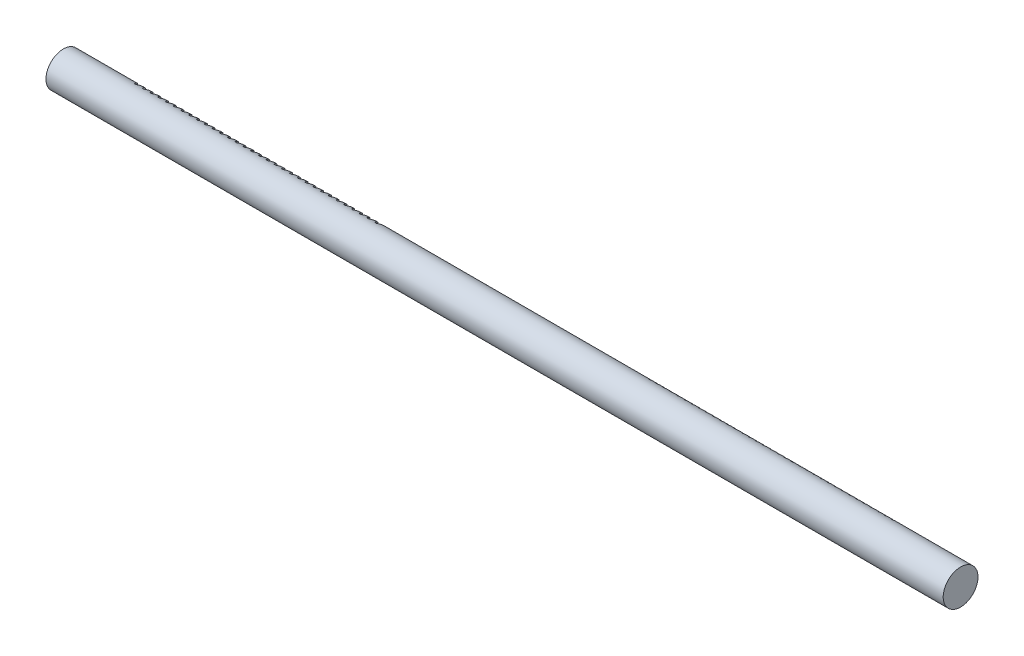
from build123d import *

# Parameters (mm, degrees)
SKIZZE2_W                                           = 670
SKIZZE2_H                                           = 13
SCHNITT_LINEAR_AUSTRAGEN1_ZAHNSTANGE_LEN_DEPTH      = 14
SCHNITT_LINEAR_AUSTRAGEN1_ZAHNSTANGE_LEN_DEPTH_BACK = 14
SCHNITT_LINEAR_AUSTRAGEN_ZAHNSTANGE_SERV_DEPTH      = 16.241670442
SCHNITT_LINEAR_AUSTRAGEN_ZAHNSTANGE_SERV_DEPTH_BACK = 16.241670442


with BuildPart() as part:
    # Skizze2 → Rotation1 (revolve)
    with BuildSketch(Plane(origin=(0, 0, 0), x_dir=(-1, 0, 0), z_dir=(0, 0, -1)), mode=Mode.PRIVATE) as rotation1_sk:
        with Locations((-308.521326768, 6.5)):
            Rectangle(SKIZZE2_W, SKIZZE2_H)
    revolve(rotation1_sk.sketch.rotate(Axis((643.521326768, 0, 0), (-1, 0, 0)), 90), axis=Axis((643.521326768, 0, 0), (-1, 0, 0)))  # turned: the seam where the file's is

    # Skizze6 → Schnitt-Linear austragen1 Zahnstange Len (cut, two sides)
    with BuildSketch(Plane(origin=(0, 0, 0), x_dir=(1, 0, 0), z_dir=(0, 1, 0))) as schnitt_linear_austragen1_zahnstange_len_sk:
        with BuildLine():
            Line((209.521326768, 13), (15.521326768, 13))
            Line((15.521326768, 13), (15.773805143, 9.389391013))
            Line((15.773805143, 9.389391013), (15.891244262, 9.14))
            Line((15.891244262, 9.14), (19.808375476, 9.14))
            Line((19.808375476, 9.14), (19.908375476, 9.04))
            Line((19.908375476, 9.04), (21.28637707, 5.253971735))
            ThreePointArc((21.28637707, 5.253971735), (21.397662113, 5.108942244), (21.572006982, 5.053971518))
            Line((21.572006982, 5.053971518), (22.55552966, 5.053971518))
            ThreePointArc((22.55552966, 5.053971518), (22.729874528, 5.108942244), (22.841159571, 5.253971735))
            Line((22.841159571, 5.253971735), (24.182764142, 8.94))
            ThreePointArc((24.182764142, 8.94), (24.294049064, 9.085029334), (24.468393743, 9.14))
            Line((24.468393743, 9.14), (25.451916422, 9.14))
            ThreePointArc((25.451916422, 9.14), (25.626261101, 9.085029334), (25.737546023, 8.94))
            Line((25.737546023, 8.94), (27.080099195, 5.251365475))
            ThreePointArc((27.080099195, 5.251365475), (27.189934051, 5.108225905), (27.362006982, 5.053971518))
            Line((27.362006982, 5.053971518), (28.34552966, 5.053971518))
            ThreePointArc((28.34552966, 5.053971518), (28.519874528, 5.108942244), (28.631159571, 5.253971735))
            Line((28.631159571, 5.253971735), (29.972764142, 8.94))
            ThreePointArc((29.972764142, 8.94), (30.084049064, 9.085029334), (30.258393743, 9.14))
            Line((30.258393743, 9.14), (31.241916422, 9.14))
            ThreePointArc((31.241916422, 9.14), (31.416261101, 9.085029334), (31.527546023, 8.94))
            Line((31.527546023, 8.94), (32.870099195, 5.251365475))
            ThreePointArc((32.870099195, 5.251365475), (32.979934051, 5.108225905), (33.152006982, 5.053971518))
            Line((33.152006982, 5.053971518), (34.13552966, 5.053971518))
            ThreePointArc((34.13552966, 5.053971518), (34.309874528, 5.108942244), (34.421159571, 5.253971735))
            Line((34.421159571, 5.253971735), (35.762764142, 8.94))
            ThreePointArc((35.762764142, 8.94), (35.874049064, 9.085029334), (36.048393743, 9.14))
            Line((36.048393743, 9.14), (37.031916422, 9.14))
            ThreePointArc((37.031916422, 9.14), (37.206261101, 9.085029334), (37.317546023, 8.94))
            Line((37.317546023, 8.94), (38.660099195, 5.251365475))
            ThreePointArc((38.660099195, 5.251365475), (38.769934051, 5.108225905), (38.942006981, 5.053971518))
            Line((38.942006981, 5.053971518), (39.92552966, 5.053971518))
            ThreePointArc((39.92552966, 5.053971518), (40.099874528, 5.108942244), (40.211159571, 5.253971735))
            Line((40.211159571, 5.253971735), (41.552764142, 8.94))
            ThreePointArc((41.552764142, 8.94), (41.664049064, 9.085029334), (41.838393743, 9.14))
            Line((41.838393743, 9.14), (42.821916422, 9.14))
            ThreePointArc((42.821916422, 9.14), (42.996261101, 9.085029334), (43.107546023, 8.94))
            Line((43.107546023, 8.94), (44.450099195, 5.251365475))
            ThreePointArc((44.450099195, 5.251365475), (44.559934051, 5.108225905), (44.732006981, 5.053971518))
            Line((44.732006981, 5.053971518), (45.71552966, 5.053971518))
            ThreePointArc((45.71552966, 5.053971518), (45.889874528, 5.108942244), (46.001159571, 5.253971735))
            Line((46.001159571, 5.253971735), (47.342764142, 8.94))
            ThreePointArc((47.342764142, 8.94), (47.454049064, 9.085029334), (47.628393743, 9.14))
            Line((47.628393743, 9.14), (48.611916422, 9.14))
            ThreePointArc((48.611916422, 9.14), (48.786261101, 9.085029334), (48.897546023, 8.94))
            Line((48.897546023, 8.94), (50.240099195, 5.251365475))
            ThreePointArc((50.240099195, 5.251365475), (50.349934051, 5.108225905), (50.522006981, 5.053971518))
            Line((50.522006981, 5.053971518), (51.50552966, 5.053971518))
            ThreePointArc((51.50552966, 5.053971518), (51.679874528, 5.108942244), (51.791159571, 5.253971735))
            Line((51.791159571, 5.253971735), (53.132764142, 8.94))
            ThreePointArc((53.132764142, 8.94), (53.244049064, 9.085029334), (53.418393743, 9.14))
            Line((53.418393743, 9.14), (54.401916422, 9.14))
            ThreePointArc((54.401916422, 9.14), (54.576261101, 9.085029334), (54.687546023, 8.94))
            Line((54.687546023, 8.94), (56.030099195, 5.251365475))
            ThreePointArc((56.030099195, 5.251365475), (56.139934051, 5.108225905), (56.312006981, 5.053971518))
            Line((56.312006981, 5.053971518), (57.29552966, 5.053971518))
            ThreePointArc((57.29552966, 5.053971518), (57.469874528, 5.108942244), (57.581159571, 5.253971735))
            Line((57.581159571, 5.253971735), (58.922764142, 8.94))
            ThreePointArc((58.922764142, 8.94), (59.034049064, 9.085029334), (59.208393743, 9.14))
            Line((59.208393743, 9.14), (60.191916422, 9.14))
            ThreePointArc((60.191916422, 9.14), (60.366261101, 9.085029334), (60.477546023, 8.94))
            Line((60.477546023, 8.94), (61.820099195, 5.251365475))
            ThreePointArc((61.820099195, 5.251365475), (61.929934051, 5.108225905), (62.102006981, 5.053971518))
            Line((62.102006981, 5.053971518), (63.08552966, 5.053971518))
            ThreePointArc((63.08552966, 5.053971518), (63.259874528, 5.108942244), (63.371159571, 5.253971735))
            Line((63.371159571, 5.253971735), (64.712764142, 8.94))
            ThreePointArc((64.712764142, 8.94), (64.824049064, 9.085029334), (64.998393743, 9.14))
            Line((64.998393743, 9.14), (65.981916422, 9.14))
            ThreePointArc((65.981916422, 9.14), (66.156261101, 9.085029334), (66.267546023, 8.94))
            Line((66.267546023, 8.94), (67.610099195, 5.251365475))
            ThreePointArc((67.610099195, 5.251365475), (67.719934051, 5.108225905), (67.892006981, 5.053971518))
            Line((67.892006981, 5.053971518), (68.87552966, 5.053971518))
            ThreePointArc((68.87552966, 5.053971518), (69.049874528, 5.108942244), (69.161159571, 5.253971735))
            Line((69.161159571, 5.253971735), (70.502764142, 8.94))
            ThreePointArc((70.502764142, 8.94), (70.614049064, 9.085029334), (70.788393743, 9.14))
            Line((70.788393743, 9.14), (71.771916422, 9.14))
            ThreePointArc((71.771916422, 9.14), (71.946261101, 9.085029334), (72.057546023, 8.94))
            Line((72.057546023, 8.94), (73.400099195, 5.251365475))
            ThreePointArc((73.400099195, 5.251365475), (73.509934051, 5.108225905), (73.682006981, 5.053971518))
            Line((73.682006981, 5.053971518), (74.66552966, 5.053971518))
            ThreePointArc((74.66552966, 5.053971518), (74.839874528, 5.108942244), (74.951159571, 5.253971735))
            Line((74.951159571, 5.253971735), (76.292764142, 8.94))
            ThreePointArc((76.292764142, 8.94), (76.404049064, 9.085029334), (76.578393743, 9.14))
            Line((76.578393743, 9.14), (77.561916422, 9.14))
            ThreePointArc((77.561916422, 9.14), (77.736261101, 9.085029334), (77.847546023, 8.94))
            Line((77.847546023, 8.94), (79.190099195, 5.251365475))
            ThreePointArc((79.190099195, 5.251365475), (79.29993405, 5.108225905), (79.472006981, 5.053971518))
            Line((79.472006981, 5.053971518), (80.45552966, 5.053971518))
            ThreePointArc((80.45552966, 5.053971518), (80.629874528, 5.108942244), (80.741159571, 5.253971735))
            Line((80.741159571, 5.253971735), (82.082764142, 8.94))
            ThreePointArc((82.082764142, 8.94), (82.194049064, 9.085029334), (82.368393743, 9.14))
            Line((82.368393743, 9.14), (83.351916422, 9.14))
            ThreePointArc((83.351916422, 9.14), (83.526261101, 9.085029334), (83.637546023, 8.94))
            Line((83.637546023, 8.94), (84.980099195, 5.251365475))
            ThreePointArc((84.980099195, 5.251365475), (85.08993405, 5.108225905), (85.262006981, 5.053971518))
            Line((85.262006981, 5.053971518), (86.24552966, 5.053971518))
            ThreePointArc((86.24552966, 5.053971518), (86.419874528, 5.108942244), (86.531159571, 5.253971735))
            Line((86.531159571, 5.253971735), (87.872764142, 8.94))
            ThreePointArc((87.872764142, 8.94), (87.984049064, 9.085029334), (88.158393743, 9.14))
            Line((88.158393743, 9.14), (89.141916422, 9.14))
            ThreePointArc((89.141916422, 9.14), (89.316261101, 9.085029334), (89.427546023, 8.94))
            Line((89.427546023, 8.94), (90.770099195, 5.251365475))
            ThreePointArc((90.770099195, 5.251365475), (90.87993405, 5.108225905), (91.052006981, 5.053971518))
            Line((91.052006981, 5.053971518), (92.03552966, 5.053971518))
            ThreePointArc((92.03552966, 5.053971518), (92.209874528, 5.108942244), (92.321159571, 5.253971735))
            Line((92.321159571, 5.253971735), (93.662764142, 8.94))
            ThreePointArc((93.662764142, 8.94), (93.774049064, 9.085029334), (93.948393743, 9.14))
            Line((93.948393743, 9.14), (94.931916422, 9.14))
            ThreePointArc((94.931916422, 9.14), (95.106261101, 9.085029334), (95.217546023, 8.94))
            Line((95.217546023, 8.94), (96.560099195, 5.251365475))
            ThreePointArc((96.560099195, 5.251365475), (96.66993405, 5.108225905), (96.842006981, 5.053971518))
            Line((96.842006981, 5.053971518), (97.82552966, 5.053971518))
            ThreePointArc((97.82552966, 5.053971518), (97.999874528, 5.108942244), (98.111159571, 5.253971735))
            Line((98.111159571, 5.253971735), (99.452764142, 8.94))
            ThreePointArc((99.452764142, 8.94), (99.564049064, 9.085029334), (99.738393743, 9.14))
            Line((99.738393743, 9.14), (100.721916422, 9.14))
            ThreePointArc((100.721916422, 9.14), (100.896261101, 9.085029334), (101.007546023, 8.94))
            Line((101.007546023, 8.94), (102.350099195, 5.251365475))
            ThreePointArc((102.350099195, 5.251365475), (102.45993405, 5.108225905), (102.632006981, 5.053971518))
            Line((102.632006981, 5.053971518), (103.61552966, 5.053971518))
            ThreePointArc((103.61552966, 5.053971518), (103.789874528, 5.108942244), (103.901159571, 5.253971735))
            Line((103.901159571, 5.253971735), (105.242764142, 8.94))
            ThreePointArc((105.242764142, 8.94), (105.354049064, 9.085029334), (105.528393743, 9.14))
            Line((105.528393743, 9.14), (106.511916422, 9.14))
            ThreePointArc((106.511916422, 9.14), (106.686261101, 9.085029334), (106.797546023, 8.94))
            Line((106.797546023, 8.94), (108.140099195, 5.251365475))
            ThreePointArc((108.140099195, 5.251365475), (108.24993405, 5.108225905), (108.422006981, 5.053971518))
            Line((108.422006981, 5.053971518), (109.40552966, 5.053971518))
            ThreePointArc((109.40552966, 5.053971518), (109.579874528, 5.108942244), (109.691159571, 5.253971735))
            Line((109.691159571, 5.253971735), (111.032764142, 8.94))
            ThreePointArc((111.032764142, 8.94), (111.144049064, 9.085029334), (111.318393743, 9.14))
            Line((111.318393743, 9.14), (112.301916422, 9.14))
            ThreePointArc((112.301916422, 9.14), (112.476261101, 9.085029334), (112.587546023, 8.94))
            Line((112.587546023, 8.94), (113.930099195, 5.251365475))
            ThreePointArc((113.930099195, 5.251365475), (114.03993405, 5.108225905), (114.212006981, 5.053971518))
            Line((114.212006981, 5.053971518), (115.19552966, 5.053971518))
            ThreePointArc((115.19552966, 5.053971518), (115.369874528, 5.108942244), (115.481159571, 5.253971735))
            Line((115.481159571, 5.253971735), (116.822764142, 8.94))
            ThreePointArc((116.822764142, 8.94), (116.934049064, 9.085029334), (117.108393743, 9.14))
            Line((117.108393743, 9.14), (118.091916422, 9.14))
            ThreePointArc((118.091916422, 9.14), (118.266261101, 9.085029334), (118.377546023, 8.94))
            Line((118.377546023, 8.94), (119.720099195, 5.251365475))
            ThreePointArc((119.720099195, 5.251365475), (119.82993405, 5.108225905), (120.002006981, 5.053971518))
            Line((120.002006981, 5.053971518), (120.98552966, 5.053971518))
            ThreePointArc((120.98552966, 5.053971518), (121.159874528, 5.108942244), (121.271159571, 5.253971735))
            Line((121.271159571, 5.253971735), (122.612764142, 8.94))
            ThreePointArc((122.612764142, 8.94), (122.724049064, 9.085029334), (122.898393743, 9.14))
            Line((122.898393743, 9.14), (123.881916422, 9.14))
            ThreePointArc((123.881916422, 9.14), (124.056261101, 9.085029334), (124.167546023, 8.94))
            Line((124.167546023, 8.94), (125.510099195, 5.251365475))
            ThreePointArc((125.510099195, 5.251365475), (125.61993405, 5.108225905), (125.792006981, 5.053971518))
            Line((125.792006981, 5.053971518), (126.77552966, 5.053971518))
            ThreePointArc((126.77552966, 5.053971518), (126.949874528, 5.108942244), (127.061159571, 5.253971735))
            Line((127.061159571, 5.253971735), (128.402764142, 8.94))
            ThreePointArc((128.402764142, 8.94), (128.514049064, 9.085029334), (128.688393743, 9.14))
            Line((128.688393743, 9.14), (129.671916422, 9.14))
            ThreePointArc((129.671916422, 9.14), (129.846261101, 9.085029334), (129.957546023, 8.94))
            Line((129.957546023, 8.94), (131.300099195, 5.251365475))
            ThreePointArc((131.300099195, 5.251365475), (131.40993405, 5.108225905), (131.582006981, 5.053971518))
            Line((131.582006981, 5.053971518), (132.56552966, 5.053971518))
            ThreePointArc((132.56552966, 5.053971518), (132.739874528, 5.108942244), (132.851159571, 5.253971735))
            Line((132.851159571, 5.253971735), (134.192764142, 8.94))
            ThreePointArc((134.192764142, 8.94), (134.304049064, 9.085029334), (134.478393743, 9.14))
            Line((134.478393743, 9.14), (135.461916422, 9.14))
            ThreePointArc((135.461916422, 9.14), (135.636261101, 9.085029334), (135.747546023, 8.94))
            Line((135.747546023, 8.94), (137.090099195, 5.251365475))
            ThreePointArc((137.090099195, 5.251365475), (137.19993405, 5.108225905), (137.372006981, 5.053971518))
            Line((137.372006981, 5.053971518), (138.35552966, 5.053971518))
            ThreePointArc((138.35552966, 5.053971518), (138.529874528, 5.108942244), (138.641159571, 5.253971735))
            Line((138.641159571, 5.253971735), (139.982764142, 8.94))
            ThreePointArc((139.982764142, 8.94), (140.094049064, 9.085029334), (140.268393743, 9.14))
            Line((140.268393743, 9.14), (141.251916421, 9.14))
            ThreePointArc((141.251916421, 9.14), (141.426261101, 9.085029334), (141.537546023, 8.94))
            Line((141.537546023, 8.94), (142.880099195, 5.251365475))
            ThreePointArc((142.880099195, 5.251365475), (142.98993405, 5.108225905), (143.162006981, 5.053971518))
            Line((143.162006981, 5.053971518), (144.14552966, 5.053971518))
            ThreePointArc((144.14552966, 5.053971518), (144.319874528, 5.108942244), (144.431159571, 5.253971735))
            Line((144.431159571, 5.253971735), (145.772764142, 8.94))
            ThreePointArc((145.772764142, 8.94), (145.884049064, 9.085029334), (146.058393743, 9.14))
            Line((146.058393743, 9.14), (147.041916421, 9.14))
            ThreePointArc((147.041916421, 9.14), (147.216261101, 9.085029334), (147.327546023, 8.94))
            Line((147.327546023, 8.94), (148.670099195, 5.251365475))
            ThreePointArc((148.670099195, 5.251365475), (148.77993405, 5.108225905), (148.952006981, 5.053971518))
            Line((148.952006981, 5.053971518), (149.93552966, 5.053971518))
            ThreePointArc((149.93552966, 5.053971518), (150.109874528, 5.108942244), (150.221159571, 5.253971735))
            Line((150.221159571, 5.253971735), (151.562764142, 8.94))
            ThreePointArc((151.562764142, 8.94), (151.674049064, 9.085029334), (151.848393743, 9.14))
            Line((151.848393743, 9.14), (152.831916421, 9.14))
            ThreePointArc((152.831916421, 9.14), (153.006261101, 9.085029334), (153.117546023, 8.94))
            Line((153.117546023, 8.94), (154.460099195, 5.251365475))
            ThreePointArc((154.460099195, 5.251365475), (154.56993405, 5.108225905), (154.742006981, 5.053971518))
            Line((154.742006981, 5.053971518), (155.72552966, 5.053971518))
            ThreePointArc((155.72552966, 5.053971518), (155.899874528, 5.108942244), (156.011159571, 5.253971735))
            Line((156.011159571, 5.253971735), (157.352764142, 8.94))
            ThreePointArc((157.352764142, 8.94), (157.464049064, 9.085029334), (157.638393743, 9.14))
            Line((157.638393743, 9.14), (158.621916421, 9.14))
            ThreePointArc((158.621916421, 9.14), (158.796261101, 9.085029334), (158.907546023, 8.94))
            Line((158.907546023, 8.94), (160.250099195, 5.251365475))
            ThreePointArc((160.250099195, 5.251365475), (160.35993405, 5.108225905), (160.532006981, 5.053971518))
            Line((160.532006981, 5.053971518), (161.51552966, 5.053971518))
            ThreePointArc((161.51552966, 5.053971518), (161.689874528, 5.108942244), (161.801159571, 5.253971735))
            Line((161.801159571, 5.253971735), (163.142764142, 8.94))
            ThreePointArc((163.142764142, 8.94), (163.254049064, 9.085029334), (163.428393743, 9.14))
            Line((163.428393743, 9.14), (164.411916421, 9.14))
            ThreePointArc((164.411916421, 9.14), (164.586261101, 9.085029334), (164.697546023, 8.94))
            Line((164.697546023, 8.94), (166.040099195, 5.251365475))
            ThreePointArc((166.040099195, 5.251365475), (166.14993405, 5.108225905), (166.322006981, 5.053971518))
            Line((166.322006981, 5.053971518), (167.305529659, 5.053971518))
            ThreePointArc((167.305529659, 5.053971518), (167.479874528, 5.108942244), (167.591159571, 5.253971735))
            Line((167.591159571, 5.253971735), (168.932764142, 8.94))
            ThreePointArc((168.932764142, 8.94), (169.044049064, 9.085029334), (169.218393743, 9.14))
            Line((169.218393743, 9.14), (170.201916421, 9.14))
            ThreePointArc((170.201916421, 9.14), (170.376261101, 9.085029334), (170.487546023, 8.94))
            Line((170.487546023, 8.94), (171.830099195, 5.251365475))
            ThreePointArc((171.830099195, 5.251365475), (171.93993405, 5.108225905), (172.112006981, 5.053971518))
            Line((172.112006981, 5.053971518), (173.095529659, 5.053971518))
            ThreePointArc((173.095529659, 5.053971518), (173.269874528, 5.108942244), (173.381159571, 5.253971735))
            Line((173.381159571, 5.253971735), (174.722764142, 8.94))
            ThreePointArc((174.722764142, 8.94), (174.834049064, 9.085029334), (175.008393743, 9.14))
            Line((175.008393743, 9.14), (175.991916421, 9.14))
            ThreePointArc((175.991916421, 9.14), (176.166261101, 9.085029334), (176.277546023, 8.94))
            Line((176.277546023, 8.94), (177.620099195, 5.251365475))
            ThreePointArc((177.620099195, 5.251365475), (177.72993405, 5.108225905), (177.902006981, 5.053971518))
            Line((177.902006981, 5.053971518), (178.885529659, 5.053971518))
            ThreePointArc((178.885529659, 5.053971518), (179.059874528, 5.108942244), (179.171159571, 5.253971735))
            Line((179.171159571, 5.253971735), (180.512764142, 8.94))
            ThreePointArc((180.512764142, 8.94), (180.624049064, 9.085029334), (180.798393743, 9.14))
            Line((180.798393743, 9.14), (181.781916421, 9.14))
            ThreePointArc((181.781916421, 9.14), (181.956261101, 9.085029334), (182.067546023, 8.94))
            Line((182.067546023, 8.94), (183.410099195, 5.251365475))
            ThreePointArc((183.410099195, 5.251365475), (183.51993405, 5.108225905), (183.692006981, 5.053971518))
            Line((183.692006981, 5.053971518), (184.675529659, 5.053971518))
            ThreePointArc((184.675529659, 5.053971518), (184.849874528, 5.108942244), (184.961159571, 5.253971735))
            Line((184.961159571, 5.253971735), (186.302764142, 8.94))
            ThreePointArc((186.302764142, 8.94), (186.414049064, 9.085029334), (186.588393743, 9.14))
            Line((186.588393743, 9.14), (187.571916421, 9.14))
            ThreePointArc((187.571916421, 9.14), (187.746261101, 9.085029334), (187.857546023, 8.94))
            Line((187.857546023, 8.94), (189.200099195, 5.251365475))
            ThreePointArc((189.200099195, 5.251365475), (189.30993405, 5.108225905), (189.482006981, 5.053971518))
            Line((189.482006981, 5.053971518), (190.465529659, 5.053971518))
            ThreePointArc((190.465529659, 5.053971518), (190.639874528, 5.108942244), (190.751159571, 5.253971735))
            Line((190.751159571, 5.253971735), (192.092764142, 8.94))
            ThreePointArc((192.092764142, 8.94), (192.204049064, 9.085029334), (192.378393743, 9.14))
            Line((192.378393743, 9.14), (193.361916421, 9.14))
            ThreePointArc((193.361916421, 9.14), (193.536261101, 9.085029334), (193.647546023, 8.94))
            Line((193.647546023, 8.94), (194.990099195, 5.251365475))
            ThreePointArc((194.990099195, 5.251365475), (195.09993405, 5.108225905), (195.272006981, 5.053971518))
            Line((195.272006981, 5.053971518), (196.255529659, 5.053971518))
            ThreePointArc((196.255529659, 5.053971518), (196.429874528, 5.108942244), (196.541159571, 5.253971735))
            Line((196.541159571, 5.253971735), (197.882764142, 8.94))
            ThreePointArc((197.882764142, 8.94), (197.994049064, 9.085029334), (198.168393743, 9.14))
            Line((198.168393743, 9.14), (199.151916421, 9.14))
            ThreePointArc((199.151916421, 9.14), (199.326261101, 9.085029334), (199.437546023, 8.94))
            Line((199.437546023, 8.94), (200.780099195, 5.251365475))
            ThreePointArc((200.780099195, 5.251365475), (200.88993405, 5.108225905), (201.062006981, 5.053971518))
            Line((201.062006981, 5.053971518), (202.045529659, 5.053971518))
            ThreePointArc((202.045529659, 5.053971518), (202.219874528, 5.108942244), (202.331159571, 5.253971735))
            Line((202.331159571, 5.253971735), (203.672764142, 8.94))
            Line((203.672764142, 8.94), (203.772764142, 9.04))
            Line((203.772764142, 9.04), (209.161898295, 9.04))
            Line((209.161898295, 9.04), (209.261898295, 9.29))
            Line((209.261898295, 9.29), (209.521326768, 13))
        make_face()
    extrude(amount=SCHNITT_LINEAR_AUSTRAGEN1_ZAHNSTANGE_LEN_DEPTH, mode=Mode.SUBTRACT)
    extrude(schnitt_linear_austragen1_zahnstange_len_sk.sketch, amount=-SCHNITT_LINEAR_AUSTRAGEN1_ZAHNSTANGE_LEN_DEPTH_BACK, mode=Mode.SUBTRACT)

    # Skizze8 → Schnitt-Linear austragen Zahnstange Serv (cut, two sides)
    with BuildSketch(Plane(origin=(0, 0, 0), x_dir=(1, 0, 0), z_dir=(0, -0.981627183, 0.190808995))) as schnitt_linear_austragen_zahnstange_serv_sk:
        with BuildLine():
            Line((409.417690096, -5.400450416), (410.608598379, -8.796620786))
            ThreePointArc((410.608598379, -8.796620786), (410.719624096, -8.943995), (410.89543493, -8.999998739))
            Line((410.89543493, -8.999998739), (411.755370858, -8.999998739))
            ThreePointArc((411.755370858, -8.999998739), (411.928243312, -8.946052476), (412.039753731, -8.803362213))
            Line((412.039753731, -8.803362213), (413.326533964, -5.393707728))
            ThreePointArc((413.326533964, -5.393707728), (413.438044383, -5.251017465), (413.610916837, -5.197071202))
            Line((413.610916837, -5.197071202), (414.470852765, -5.197071202))
            ThreePointArc((414.470852765, -5.197071202), (414.646663221, -5.253074551), (414.757689056, -5.400448112))
            Line((414.757689056, -5.400448112), (415.948597599, -8.796619525))
            ThreePointArc((415.948597599, -8.796619525), (416.059623315, -8.943993739), (416.23543415, -8.999997478))
            Line((416.23543415, -8.999997478), (417.095370077, -8.999997478))
            ThreePointArc((417.095370077, -8.999997478), (417.268242532, -8.946051215), (417.37975295, -8.803360952))
            Line((417.37975295, -8.803360952), (418.666533183, -5.393706467))
            ThreePointArc((418.666533183, -5.393706467), (418.778043602, -5.251016204), (418.950916056, -5.197069941))
            Line((418.950916056, -5.197069941), (419.810851984, -5.197069941))
            ThreePointArc((419.810851984, -5.197069941), (419.986662296, -5.253073432), (420.097688063, -5.400446851))
            Line((420.097688063, -5.400446851), (421.288596818, -8.796618264))
            ThreePointArc((421.288596818, -8.796618264), (421.399622534, -8.943992477), (421.575433369, -8.999996216))
            Line((421.575433369, -8.999996216), (422.435369297, -8.999996216))
            ThreePointArc((422.435369297, -8.999996216), (422.608241751, -8.946049954), (422.719752169, -8.803359691))
            Line((422.719752169, -8.803359691), (424.006532403, -5.393705206))
            ThreePointArc((424.006532403, -5.393705206), (424.118042821, -5.251014943), (424.290915275, -5.19706868))
            Line((424.290915275, -5.19706868), (425.150851203, -5.19706868))
            ThreePointArc((425.150851203, -5.19706868), (425.326661515, -5.253072171), (425.437687283, -5.40044559))
            Line((425.437687283, -5.40044559), (426.628596037, -8.796617003))
            ThreePointArc((426.628596037, -8.796617003), (426.739621753, -8.943991216), (426.915432588, -8.999994955))
            Line((426.915432588, -8.999994955), (427.775368516, -8.999994955))
            ThreePointArc((427.775368516, -8.999994955), (427.94824097, -8.946048693), (428.059751388, -8.803358429))
            Line((428.059751388, -8.803358429), (429.346531622, -5.393703945))
            ThreePointArc((429.346531622, -5.393703945), (429.45804204, -5.251013682), (429.630914494, -5.197067419))
            Line((429.630914494, -5.197067419), (430.490850422, -5.197067419))
            ThreePointArc((430.490850422, -5.197067419), (430.666660734, -5.25307091), (430.777686502, -5.400444329))
            Line((430.777686502, -5.400444329), (431.968595256, -8.796615742))
            ThreePointArc((431.968595256, -8.796615742), (432.079620972, -8.943989955), (432.255431807, -8.999993694))
            Line((432.255431807, -8.999993694), (433.115367735, -8.999993694))
            ThreePointArc((433.115367735, -8.999993694), (433.288240189, -8.946047431), (433.399750608, -8.803357168))
            Line((433.399750608, -8.803357168), (434.686530841, -5.393702684))
            ThreePointArc((434.686530841, -5.393702684), (434.798041259, -5.25101242), (434.970913713, -5.197066158))
            Line((434.970913713, -5.197066158), (435.830849641, -5.197066158))
            ThreePointArc((435.830849641, -5.197066158), (436.006659954, -5.253069649), (436.117685721, -5.400443068))
            Line((436.117685721, -5.400443068), (437.308594475, -8.79661448))
            ThreePointArc((437.308594475, -8.79661448), (437.419620192, -8.943988694), (437.595431026, -8.999992433))
            Line((437.595431026, -8.999992433), (438.455366954, -8.999992433))
            ThreePointArc((438.455366954, -8.999992433), (438.628239408, -8.94604617), (438.739749827, -8.803355907))
            Line((438.739749827, -8.803355907), (440.02653006, -5.393701422))
            ThreePointArc((440.02653006, -5.393701422), (440.138040479, -5.251011159), (440.310912933, -5.197064896))
            Line((440.310912933, -5.197064896), (441.170848861, -5.197064896))
            ThreePointArc((441.170848861, -5.197064896), (441.346659173, -5.253068388), (441.45768494, -5.400441807))
            Line((441.45768494, -5.400441807), (442.648593695, -8.796613219))
            ThreePointArc((442.648593695, -8.796613219), (442.759619411, -8.943987433), (442.935430246, -8.999991172))
            Line((442.935430246, -8.999991172), (443.795366174, -8.999991172))
            ThreePointArc((443.795366174, -8.999991172), (443.968238628, -8.946044909), (444.079749046, -8.803354646))
            Line((444.079749046, -8.803354646), (445.366529279, -5.393700161))
            ThreePointArc((445.366529279, -5.393700161), (445.478039698, -5.251009898), (445.650912152, -5.197063635))
            Line((445.650912152, -5.197063635), (446.51084808, -5.197063635))
            ThreePointArc((446.51084808, -5.197063635), (446.686658392, -5.253067126), (446.797684159, -5.400440545))
            Line((446.797684159, -5.400440545), (447.988592914, -8.796611958))
            ThreePointArc((447.988592914, -8.796611958), (448.09961863, -8.943986171), (448.275429465, -8.999989911))
            Line((448.275429465, -8.999989911), (449.135365393, -8.999989911))
            ThreePointArc((449.135365393, -8.999989911), (449.308237847, -8.946043648), (449.419748265, -8.803353385))
            Line((449.419748265, -8.803353385), (450.706528499, -5.3936989))
            ThreePointArc((450.706528499, -5.3936989), (450.818038917, -5.251008637), (450.990911371, -5.197062374))
            Line((450.990911371, -5.197062374), (451.850847299, -5.197062374))
            ThreePointArc((451.850847299, -5.197062374), (452.026657611, -5.253065865), (452.137683379, -5.400439284))
            Line((452.137683379, -5.400439284), (453.328592133, -8.796610697))
            ThreePointArc((453.328592133, -8.796610697), (453.439617849, -8.94398491), (453.615428684, -8.999988649))
            Line((453.615428684, -8.999988649), (454.475364612, -8.999988649))
            ThreePointArc((454.475364612, -8.999988649), (454.648237066, -8.946042387), (454.759747484, -8.803352123))
            Line((454.759747484, -8.803352123), (456.046527718, -5.393697639))
            ThreePointArc((456.046527718, -5.393697639), (456.158038136, -5.251007376), (456.33091059, -5.197061113))
            Line((456.33091059, -5.197061113), (457.190846518, -5.197061113))
            ThreePointArc((457.190846518, -5.197061113), (457.36665683, -5.253064604), (457.477682598, -5.400438023))
            Line((457.477682598, -5.400438023), (458.668591352, -8.796609436))
            ThreePointArc((458.668591352, -8.796609436), (458.779617068, -8.943983649), (458.955427903, -8.999987388))
            Line((458.955427903, -8.999987388), (459.815363831, -8.999987388))
            ThreePointArc((459.815363831, -8.999987388), (459.988236285, -8.946041126), (460.099746704, -8.803350862))
            Line((460.099746704, -8.803350862), (461.386526937, -5.393696378))
            ThreePointArc((461.386526937, -5.393696378), (461.498037355, -5.251006114), (461.67090981, -5.197059852))
            Line((461.67090981, -5.197059852), (462.530845737, -5.197059852))
            ThreePointArc((462.530845737, -5.197059852), (462.70665605, -5.253063343), (462.817681817, -5.400436762))
            Line((462.817681817, -5.400436762), (464.008590571, -8.796608175))
            ThreePointArc((464.008590571, -8.796608175), (464.119616288, -8.943982388), (464.295427122, -8.999986127))
            Line((464.295427122, -8.999986127), (465.15536305, -8.999986127))
            ThreePointArc((465.15536305, -8.999986127), (465.328235504, -8.946039864), (465.439745923, -8.803349601))
            Line((465.439745923, -8.803349601), (466.726526156, -5.393695117))
            ThreePointArc((466.726526156, -5.393695117), (466.838036575, -5.251004853), (467.010909029, -5.197058591))
            Line((467.010909029, -5.197058591), (467.870844957, -5.197058591))
            ThreePointArc((467.870844957, -5.197058591), (468.046655269, -5.253062082), (468.157681036, -5.400435501))
            Line((468.157681036, -5.400435501), (469.348589791, -8.796606913))
            ThreePointArc((469.348589791, -8.796606913), (469.459615507, -8.943981127), (469.635426342, -8.999984866))
            Line((469.635426342, -8.999984866), (470.49536227, -8.999984866))
            ThreePointArc((470.49536227, -8.999984866), (470.668234724, -8.946038603), (470.779745142, -8.80334834))
            Line((470.779745142, -8.80334834), (472.066525375, -5.393693855))
            ThreePointArc((472.066525375, -5.393693855), (472.178035794, -5.251003592), (472.350908248, -5.197057329))
            Line((472.350908248, -5.197057329), (473.210844176, -5.197057329))
            ThreePointArc((473.210844176, -5.197057329), (473.386654488, -5.25306082), (473.497680255, -5.40043424))
            Line((473.497680255, -5.40043424), (474.68858901, -8.796605652))
            ThreePointArc((474.68858901, -8.796605652), (474.799614726, -8.943979866), (474.975425561, -8.999983605))
            Line((474.975425561, -8.999983605), (475.835361489, -8.999983605))
            ThreePointArc((475.835361489, -8.999983605), (476.008233943, -8.946037342), (476.119744361, -8.803347079))
            Line((476.119744361, -8.803347079), (477.406524595, -5.393692594))
            ThreePointArc((477.406524595, -5.393692594), (477.518035013, -5.251002331), (477.690907467, -5.197056068))
            Line((477.690907467, -5.197056068), (478.550843395, -5.197056068))
            ThreePointArc((478.550843395, -5.197056068), (478.726653707, -5.253059559), (478.837679475, -5.400432978))
            Line((478.837679475, -5.400432978), (480.028588229, -8.796604391))
            ThreePointArc((480.028588229, -8.796604391), (480.139613945, -8.943978604), (480.31542478, -8.999982344))
            Line((480.31542478, -8.999982344), (481.175360708, -8.999982344))
            ThreePointArc((481.175360708, -8.999982344), (481.348233162, -8.946036081), (481.45974358, -8.803345818))
            Line((481.45974358, -8.803345818), (482.746523814, -5.393691333))
            ThreePointArc((482.746523814, -5.393691333), (482.858034232, -5.25100107), (483.030906686, -5.197054807))
            Line((483.030906686, -5.197054807), (483.890842614, -5.197054807))
            ThreePointArc((483.890842614, -5.197054807), (484.066652926, -5.253058298), (484.177678694, -5.400431717))
            Line((484.177678694, -5.400431717), (485.368587448, -8.79660313))
            ThreePointArc((485.368587448, -8.79660313), (485.479613164, -8.943977343), (485.655423999, -8.999981082))
            Line((485.655423999, -8.999981082), (486.515359927, -8.999981082))
            ThreePointArc((486.515359927, -8.999981082), (486.688232381, -8.94603482), (486.7997428, -8.803344556))
            Line((486.7997428, -8.803344556), (488.086523033, -5.393690072))
            ThreePointArc((488.086523033, -5.393690072), (488.198033451, -5.250999809), (488.370905906, -5.197053546))
            Line((488.370905906, -5.197053546), (489.230841833, -5.197053546))
            ThreePointArc((489.230841833, -5.197053546), (489.406652146, -5.253057037), (489.517677913, -5.400430456))
            Line((489.517677913, -5.400430456), (490.708586667, -8.796601869))
            ThreePointArc((490.708586667, -8.796601869), (490.819612384, -8.943976082), (490.995423219, -8.999979821))
            Line((490.995423219, -8.999979821), (491.855359146, -8.999979821))
            ThreePointArc((491.855359146, -8.999979821), (492.0282316, -8.946033558), (492.139742019, -8.803343295))
            Line((492.139742019, -8.803343295), (493.426522252, -5.393688811))
            ThreePointArc((493.426522252, -5.393688811), (493.538032671, -5.250998547), (493.710905125, -5.197052285))
            Line((493.710905125, -5.197052285), (494.570841053, -5.197052285))
            ThreePointArc((494.570841053, -5.197052285), (494.746651365, -5.253055776), (494.857677132, -5.400429195))
            Line((494.857677132, -5.400429195), (496.048585887, -8.796600607))
            ThreePointArc((496.048585887, -8.796600607), (496.159611603, -8.943974821), (496.335422438, -8.99997856))
            Line((496.335422438, -8.99997856), (497.195358366, -8.99997856))
            ThreePointArc((497.195358366, -8.99997856), (497.36823082, -8.946032297), (497.479741238, -8.803342034))
            Line((497.479741238, -8.803342034), (498.766521471, -5.393687549))
            ThreePointArc((498.766521471, -5.393687549), (498.87803189, -5.250997286), (499.050904344, -5.197051023))
            Line((499.050904344, -5.197051023), (499.910840272, -5.197051023))
            ThreePointArc((499.910840272, -5.197051023), (500.086650584, -5.253054515), (500.197676351, -5.400427934))
            Line((500.197676351, -5.400427934), (501.388585106, -8.796599346))
            ThreePointArc((501.388585106, -8.796599346), (501.499610822, -8.94397356), (501.675421657, -8.999977299))
            Line((501.675421657, -8.999977299), (502.535357585, -8.999977299))
            ThreePointArc((502.535357585, -8.999977299), (502.708230039, -8.946031036), (502.819740457, -8.803340773))
            Line((502.819740457, -8.803340773), (504.106520691, -5.393686288))
            ThreePointArc((504.106520691, -5.393686288), (504.218031109, -5.250996025), (504.390903563, -5.197049762))
            Line((504.390903563, -5.197049762), (505.250839491, -5.197049762))
            ThreePointArc((505.250839491, -5.197049762), (505.426649803, -5.253053253), (505.537675571, -5.400426672))
            Line((505.537675571, -5.400426672), (506.728584325, -8.796598085))
            ThreePointArc((506.728584325, -8.796598085), (506.839610041, -8.943972299), (507.015420876, -8.999976038))
            Line((507.015420876, -8.999976038), (507.875356804, -8.999976038))
            ThreePointArc((507.875356804, -8.999976038), (508.048229258, -8.946029775), (508.159739676, -8.803339512))
            Line((508.159739676, -8.803339512), (509.44651991, -5.393685027))
            ThreePointArc((509.44651991, -5.393685027), (509.558030328, -5.250994764), (509.730902782, -5.197048501))
            Line((509.730902782, -5.197048501), (510.59083871, -5.197048501))
            ThreePointArc((510.59083871, -5.197048501), (510.766649022, -5.253051992), (510.87767479, -5.400425411))
            Line((510.87767479, -5.400425411), (512.068583544, -8.796596824))
            ThreePointArc((512.068583544, -8.796596824), (512.17960926, -8.943971037), (512.355420095, -8.999974776))
            Line((512.355420095, -8.999974776), (513.215356023, -8.999974776))
            ThreePointArc((513.215356023, -8.999974776), (513.388228477, -8.946028514), (513.499738896, -8.80333825))
            Line((513.499738896, -8.80333825), (514.786519129, -5.393683766))
            ThreePointArc((514.786519129, -5.393683766), (514.898029548, -5.250993503), (515.070902002, -5.19704724))
            Line((515.070902002, -5.19704724), (515.930837929, -5.19704724))
            ThreePointArc((515.930837929, -5.19704724), (516.106648242, -5.253050731), (516.217674009, -5.40042415))
            Line((516.217674009, -5.40042415), (517.408582763, -8.796595563))
            ThreePointArc((517.408582763, -8.796595563), (517.51960848, -8.943969776), (517.695419315, -8.999973515))
            Line((517.695419315, -8.999973515), (518.555355242, -8.999973515))
            ThreePointArc((518.555355242, -8.999973515), (518.728227696, -8.946027253), (518.839738115, -8.803336989))
            Line((518.839738115, -8.803336989), (520.126518348, -5.393682505))
            ThreePointArc((520.126518348, -5.393682505), (520.238028767, -5.250992241), (520.410901221, -5.197045979))
            Line((520.410901221, -5.197045979), (521.270837149, -5.197045979))
            ThreePointArc((521.270837149, -5.197045979), (521.446647461, -5.25304947), (521.557673228, -5.400422889))
            Line((521.557673228, -5.400422889), (522.748581983, -8.796594302))
            ThreePointArc((522.748581983, -8.796594302), (522.859607699, -8.943968515), (523.035418534, -8.999972254))
            Line((523.035418534, -8.999972254), (523.895354462, -8.999972254))
            ThreePointArc((523.895354462, -8.999972254), (524.068226916, -8.946025991), (524.179737334, -8.803335728))
            Line((524.179737334, -8.803335728), (525.466517568, -5.393681244))
            ThreePointArc((525.466517568, -5.393681244), (525.578027986, -5.25099098), (525.75090044, -5.197044718))
            Line((525.75090044, -5.197044718), (526.610836368, -5.197044718))
            ThreePointArc((526.610836368, -5.197044718), (526.78664668, -5.253048209), (526.897672448, -5.400421628))
            Line((526.897672448, -5.400421628), (528.088581202, -8.79659304))
            ThreePointArc((528.088581202, -8.79659304), (528.199606918, -8.943967254), (528.375417753, -8.999970993))
            Line((528.375417753, -8.999970993), (529.235353681, -8.999970993))
            ThreePointArc((529.235353681, -8.999970993), (529.408226135, -8.94602473), (529.519736553, -8.803334467))
            Line((529.519736553, -8.803334467), (530.806516787, -5.393679982))
            ThreePointArc((530.806516787, -5.393679982), (530.918027205, -5.250989719), (531.090899659, -5.197043456))
            Line((531.090899659, -5.197043456), (531.950835587, -5.197043456))
            ThreePointArc((531.950835587, -5.197043456), (532.126645899, -5.253046947), (532.237671667, -5.400420367))
            Line((532.237671667, -5.400420367), (533.428580421, -8.796591779))
            ThreePointArc((533.428580421, -8.796591779), (533.539606137, -8.943965993), (533.715416972, -8.999969732))
            Line((533.715416972, -8.999969732), (534.5753529, -8.999969732))
            ThreePointArc((534.5753529, -8.999969732), (534.748225354, -8.946023469), (534.859735773, -8.803333206))
            Line((534.859735773, -8.803333206), (536.146516006, -5.393678721))
            ThreePointArc((536.146516006, -5.393678721), (536.258026424, -5.250988458), (536.430898878, -5.197042195))
            Line((536.430898878, -5.197042195), (537.290834806, -5.197042195))
            ThreePointArc((537.290834806, -5.197042195), (537.466645118, -5.253045686), (537.577670886, -5.400419105))
            Line((537.577670886, -5.400419105), (538.76857964, -8.796590518))
            ThreePointArc((538.76857964, -8.796590518), (538.879605357, -8.943964731), (539.055416191, -8.999968471))
            Line((539.055416191, -8.999968471), (539.915352119, -8.999968471))
            ThreePointArc((539.915352119, -8.999968471), (540.088224573, -8.946022208), (540.199734992, -8.803331945))
            Line((540.199734992, -8.803331945), (541.486515225, -5.39367746))
            ThreePointArc((541.486515225, -5.39367746), (541.598025644, -5.250987197), (541.770898098, -5.197040934))
            Line((541.770898098, -5.197040934), (542.630834026, -5.197040934))
            ThreePointArc((542.630834026, -5.197040934), (542.806644338, -5.253044425), (542.917670105, -5.400417844))
            Line((542.917670105, -5.400417844), (544.10857886, -8.796589257))
            ThreePointArc((544.10857886, -8.796589257), (544.219604576, -8.94396347), (544.395415411, -8.999967209))
            Line((544.395415411, -8.999967209), (545.255351338, -8.999967209))
            ThreePointArc((545.255351338, -8.999967209), (545.428223793, -8.946020947), (545.539734211, -8.803330683))
            Line((545.539734211, -8.803330683), (546.826514444, -5.393676199))
            ThreePointArc((546.826514444, -5.393676199), (546.938024863, -5.250985936), (547.110897317, -5.197039673))
            Line((547.110897317, -5.197039673), (547.970833245, -5.197039673))
            ThreePointArc((547.970833245, -5.197039673), (548.146643557, -5.253043164), (548.257669324, -5.400416583))
            Line((548.257669324, -5.400416583), (549.448578079, -8.796587996))
            ThreePointArc((549.448578079, -8.796587996), (549.559603795, -8.943962209), (549.73541463, -8.999965948))
            Line((549.73541463, -8.999965948), (550.595350558, -8.999965948))
            ThreePointArc((550.595350558, -8.999965948), (550.768223012, -8.946019685), (550.87973343, -8.803329422))
            Line((550.87973343, -8.803329422), (552.166513664, -5.393674938))
            ThreePointArc((552.166513664, -5.393674938), (552.278024082, -5.250984674), (552.450896536, -5.197038412))
            Line((552.450896536, -5.197038412), (553.310832464, -5.197038412))
            ThreePointArc((553.310832464, -5.197038412), (553.486642776, -5.253041903), (553.597668544, -5.400415322))
            Line((553.597668544, -5.400415322), (554.788577298, -8.796586735))
            ThreePointArc((554.788577298, -8.796586735), (554.899603014, -8.943960948), (555.075413849, -8.999964687))
            Line((555.075413849, -8.999964687), (555.935349777, -8.999964687))
            ThreePointArc((555.935349777, -8.999964687), (556.108222231, -8.946018424), (556.219732649, -8.803328161))
            Line((556.219732649, -8.803328161), (557.506512883, -5.393673676))
            ThreePointArc((557.506512883, -5.393673676), (557.618023301, -5.250983413), (557.790895755, -5.197037151))
            Line((557.790895755, -5.197037151), (558.650831683, -5.197037151))
            ThreePointArc((558.650831683, -5.197037151), (558.826641995, -5.253040642), (558.937667763, -5.400414061))
            Line((558.937667763, -5.400414061), (560.128576517, -8.796585473))
            ThreePointArc((560.128576517, -8.796585473), (560.239602233, -8.943959687), (560.415413068, -8.999963426))
            Line((560.415413068, -8.999963426), (561.275348996, -8.999963426))
            ThreePointArc((561.275348996, -8.999963426), (561.44822145, -8.946017163), (561.559731869, -8.8033269))
            Line((561.559731869, -8.8033269), (562.846512102, -5.393672415))
            ThreePointArc((562.846512102, -5.393672415), (562.95802252, -5.250982152), (563.130894974, -5.197035889))
            Line((563.130894974, -5.197035889), (563.990830902, -5.197035889))
            ThreePointArc((563.990830902, -5.197035889), (564.166641215, -5.25303938), (564.277666982, -5.4004128))
            Line((564.277666982, -5.4004128), (565.468575736, -8.796584212))
            ThreePointArc((565.468575736, -8.796584212), (565.579601453, -8.943958426), (565.755412287, -8.999962165))
            Line((565.755412287, -8.999962165), (566.615348215, -8.999962165))
            ThreePointArc((566.615348215, -8.999962165), (566.788220669, -8.946015902), (566.899731088, -8.803325639))
            Line((566.899731088, -8.803325639), (568.186511321, -5.393671154))
            ThreePointArc((568.186511321, -5.393671154), (568.29802174, -5.250980891), (568.470894194, -5.197034628))
            Line((568.470894194, -5.197034628), (569.330830122, -5.197034628))
            ThreePointArc((569.330830122, -5.197034628), (569.506640434, -5.253038119), (569.617666201, -5.400411538))
            Line((569.617666201, -5.400411538), (570.808574956, -8.796582951))
            ThreePointArc((570.808574956, -8.796582951), (570.919600672, -8.943957164), (571.095411507, -8.999960903))
            Line((571.095411507, -8.999960903), (571.955347434, -8.999960903))
            ThreePointArc((571.955347434, -8.999960903), (572.128219889, -8.946014641), (572.239730307, -8.803324378))
            Line((572.239730307, -8.803324378), (573.52651054, -5.393669893))
            ThreePointArc((573.52651054, -5.393669893), (573.638020959, -5.25097963), (573.810893413, -5.197033367))
            Line((573.810893413, -5.197033367), (574.670829341, -5.197033367))
            ThreePointArc((574.670829341, -5.197033367), (574.846639653, -5.253036858), (574.95766542, -5.400410277))
            Line((574.95766542, -5.400410277), (576.148574175, -8.79658169))
            ThreePointArc((576.148574175, -8.79658169), (576.259599891, -8.943955903), (576.435410726, -8.999959642))
            Line((576.435410726, -8.999959642), (577.295346654, -8.999959642))
            ThreePointArc((577.295346654, -8.999959642), (577.468219108, -8.94601338), (577.579729526, -8.803323116))
            Line((577.579729526, -8.803323116), (578.86650976, -5.393668632))
            ThreePointArc((578.86650976, -5.393668632), (578.978020178, -5.250978369), (579.150892632, -5.197032106))
            Line((579.150892632, -5.197032106), (580.01082856, -5.197032106))
            ThreePointArc((580.01082856, -5.197032106), (580.186638872, -5.253035597), (580.29766464, -5.400409016))
            Line((580.29766464, -5.400409016), (581.488573394, -8.796580429))
            ThreePointArc((581.488573394, -8.796580429), (581.59959911, -8.943954642), (581.775409945, -8.999958381))
            Line((581.775409945, -8.999958381), (582.635345873, -8.999958381))
            ThreePointArc((582.635345873, -8.999958381), (582.808218327, -8.946012118), (582.919728745, -8.803321855))
            Line((582.919728745, -8.803321855), (584.206508979, -5.393667371))
            ThreePointArc((584.206508979, -5.393667371), (584.318019397, -5.250977107), (584.490891851, -5.197030845))
            Line((584.490891851, -5.197030845), (585.350827779, -5.197030845))
            ThreePointArc((585.350827779, -5.197030845), (585.526638614, -5.253034584), (585.63766433, -5.400408797))
            Line((585.63766433, -5.400408797), (586.86483849, -8.9))
            Line((586.86483849, -8.9), (586.96483849, -9))
            Line((586.96483849, -9), (590.583094988, -9))
            Line((590.583094988, -9), (590.683094988, -9.25))
            Line((590.683094988, -9.25), (591.242802281, -13))
            Line((591.242802281, -13), (397.242802281, -13))
            Line((397.242802281, -13), (397.505027826, -9.25))
            Line((397.505027826, -9.25), (397.605027826, -9))
            Line((397.605027826, -9), (401.223284324, -9))
            Line((401.223284324, -9), (401.323284324, -8.9))
            Line((401.323284324, -8.9), (402.64653444, -5.393709201))
            ThreePointArc((402.64653444, -5.393709201), (402.758044978, -5.251018784), (402.930917618, -5.197072464))
            Line((402.930917618, -5.197072464), (403.790853546, -5.197072464))
            ThreePointArc((403.790853546, -5.197072464), (403.96666457, -5.253076263), (404.077690406, -5.400450635))
            Line((404.077690406, -5.400450635), (405.26859916, -8.796622048))
            ThreePointArc((405.26859916, -8.796622048), (405.379624876, -8.943996261), (405.555435711, -9))
            Line((405.555435711, -9), (406.415371639, -9))
            ThreePointArc((406.415371639, -9), (406.588244093, -8.946053737), (406.699754512, -8.803363474))
            Line((406.699754512, -8.803363474), (407.986534745, -5.393708989))
            ThreePointArc((407.986534745, -5.393708989), (408.098045163, -5.251018726), (408.270917617, -5.197072464))
            Line((408.270917617, -5.197072464), (409.130853545, -5.197072464))
            ThreePointArc((409.130853545, -5.197072464), (409.30666438, -5.253076203), (409.417690096, -5.400450416))
        make_face()
    extrude(amount=SCHNITT_LINEAR_AUSTRAGEN_ZAHNSTANGE_SERV_DEPTH, mode=Mode.SUBTRACT)
    extrude(schnitt_linear_austragen_zahnstange_serv_sk.sketch, amount=-SCHNITT_LINEAR_AUSTRAGEN_ZAHNSTANGE_SERV_DEPTH_BACK, mode=Mode.SUBTRACT)


solid = part.part
